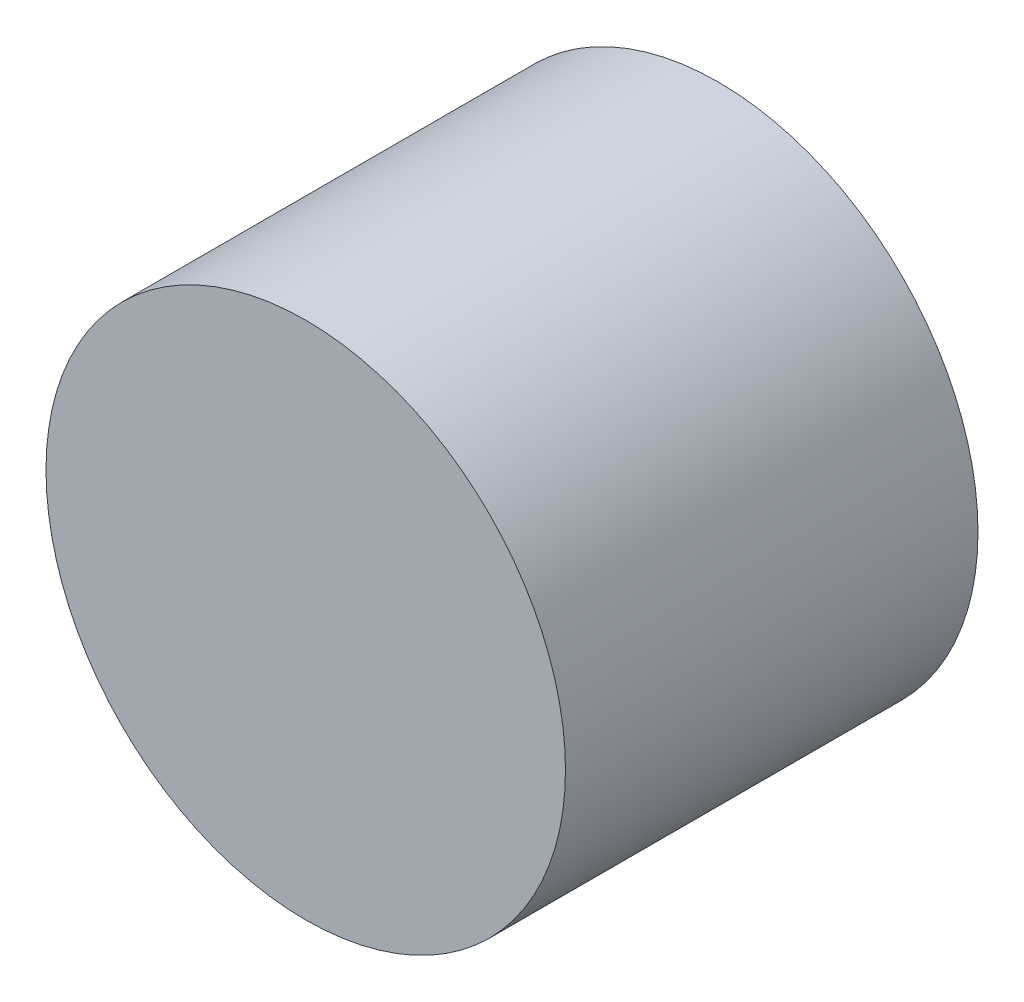
from build123d import *

# Parameters (mm, degrees)
SKETCH1_R           = 8.5
BOSS_EXTRUDE1_DEPTH = 13.5


with BuildPart() as part:
    # Sketch1 → Boss-Extrude1 (new body)
    with BuildSketch(Plane.XY):
        Circle(SKETCH1_R)
    extrude(amount=BOSS_EXTRUDE1_DEPTH)


solid = part.part
